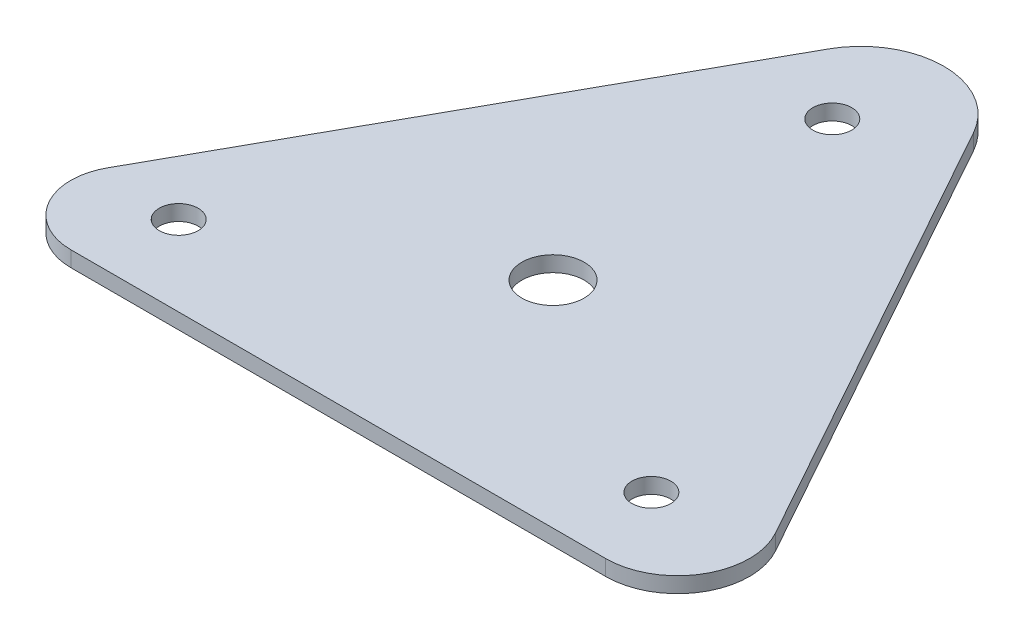
from build123d import *

# Parameters (mm, degrees)
SKETCH1_R           = 3.96875
SKETCH1_R_2         = 6.35
BOSS_EXTRUDE1_DEPTH = 3.175


with BuildPart() as part:
    # Sketch1 → Boss-Extrude1 (new body)
    with BuildSketch(Plane(origin=(0, 0, 0), x_dir=(1, 0, 0), z_dir=(0, 1, 0))):
        with BuildLine():
            Line((0, 0), (109.1184, 0))
            ThreePointArc((109.1184, 0), (121.760823269, 7.229815564), (121.940842268, 21.792394057))
            Line((121.940842268, 21.792394057), (71.401285641, 112.759573229))
            ThreePointArc((71.401285641, 112.759573229), (56.609708232, 121.4628), (41.818130824, 112.759573229))
            Line((41.818130824, 112.759573229), (-10.713122761, 18.207498065))
            ThreePointArc((-10.713122761, 18.207498065), (-10.562717277, 6.040495255), (0, 0))
        make_face()
        with Locations((5.658509088, 16.357983524)):
            Circle(SKETCH1_R, mode=Mode.SUBTRACT)
        with Locations((102.076909088, 16.357983524)):
            Circle(SKETCH1_R, mode=Mode.SUBTRACT)
        with Locations((54.5592, 100.77924387)):
            Circle(SKETCH1_R, mode=Mode.SUBTRACT)
        with Locations((54.5592, 43.812190688)):
            Circle(SKETCH1_R_2, mode=Mode.SUBTRACT)
    extrude(amount=BOSS_EXTRUDE1_DEPTH)


solid = part.part
